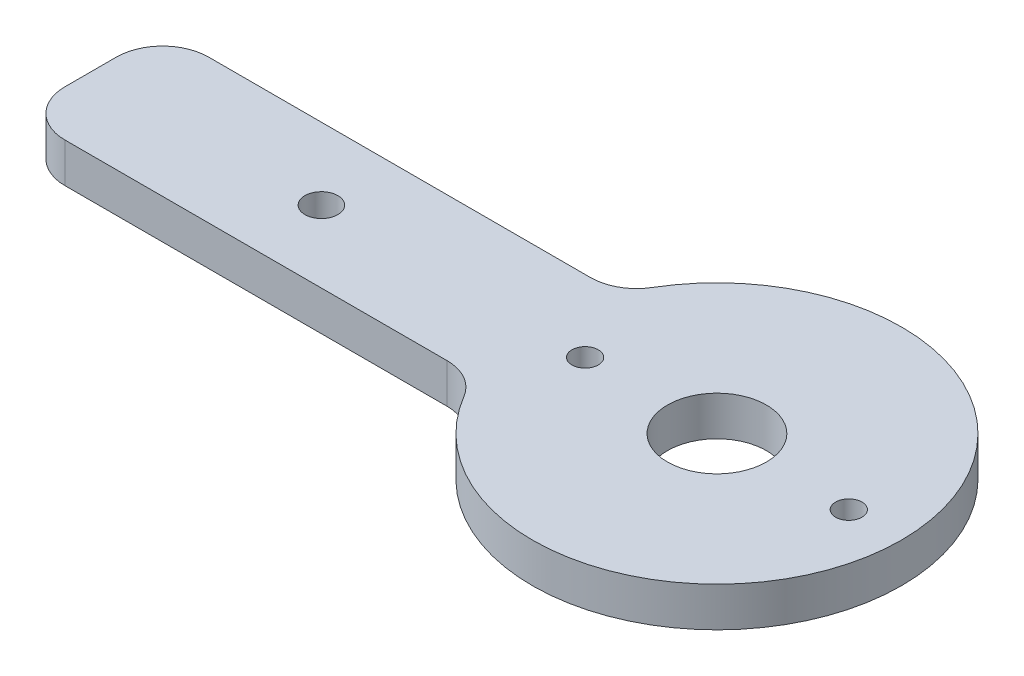
from build123d import *

# Parameters (mm, degrees)
ESQUISSE1_R        = 2
ESQUISSE1_R_2      = 7.5
ESQUISSE1_R_3      = 2.5
BOSS_EXTRU_1_DEPTH = 6


with BuildPart() as part:
    # Esquisse1 → Boss.-Extru.1 (new body)
    with BuildSketch(Plane(origin=(0, 0, 0), x_dir=(1, 0, 0), z_dir=(0, 1, 0))):
        with BuildLine():
            Line((-74.229814571, -3.895021171), (-74.229814571, 3.895021171))
            ThreePointArc((-74.229814571, 3.895021171), (-72.17956204, 8.844768639), (-67.229814571, 10.895021171))
            Line((-67.229814571, 10.895021171), (-9.309179879, 10.895021171))
            ThreePointArc((-9.309179879, 10.895021171), (-5.848907465, 11.810079526), (-3.293306817, 14.316016937))
            ThreePointArc((-3.293306817, 14.316016937), (48.770185429, 0), (-3.293306817, -14.316016937))
            ThreePointArc((-3.293306817, -14.316016937), (-5.848907465, -11.810079526), (-9.309179879, -10.895021171))
            Line((-9.309179879, -10.895021171), (-67.229814571, -10.895021171))
            ThreePointArc((-67.229814571, -10.895021171), (-72.17956204, -8.844768639), (-74.229814571, -3.895021171))
        make_face()
        with Locations((40.770185429, 0)):
            Circle(ESQUISSE1_R, mode=Mode.SUBTRACT)
        with Locations((20.770185429, 0)):
            Circle(ESQUISSE1_R_2, mode=Mode.SUBTRACT)
        with Locations((0.770185429, 0)):
            Circle(ESQUISSE1_R, mode=Mode.SUBTRACT)
        with Locations((-39.229814571, 0)):
            Circle(ESQUISSE1_R_3, mode=Mode.SUBTRACT)
    extrude(amount=BOSS_EXTRU_1_DEPTH)


solid = part.part
